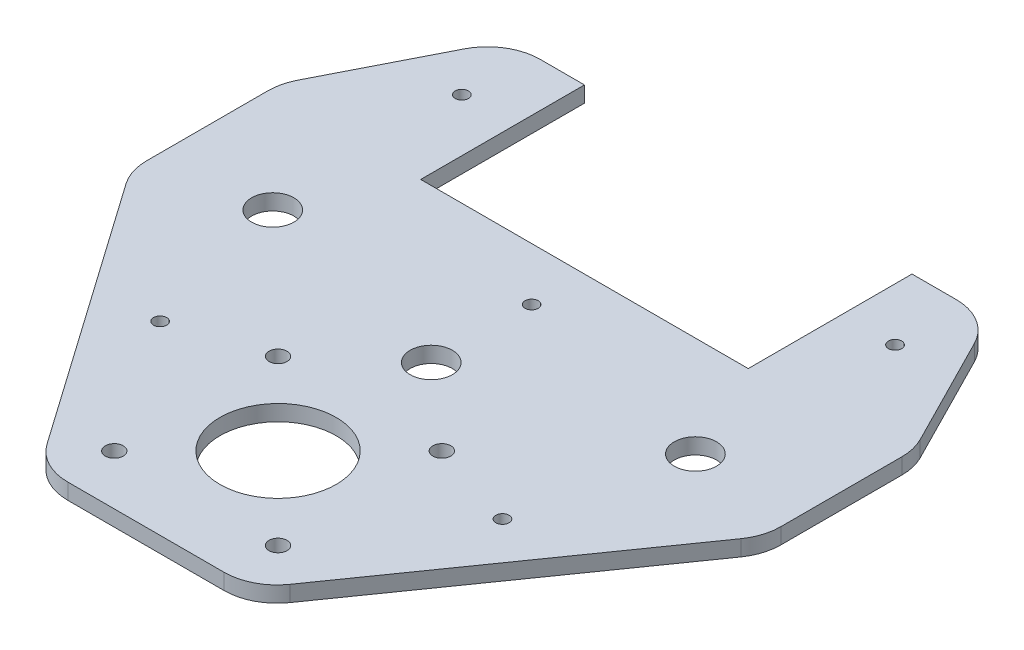
from build123d import *

# Parameters (mm, degrees)
SKETCH1_R           = 4
SKETCH1_R_2         = 1.7
SKETCH1_R_3         = 11
BOSS_EXTRUDE1_DEPTH = 3
FILLET1_R           = 10
SKETCH2_R           = 1.25
SKETCH2_R_2         = 1.255555556
CUT_EXTRUDE1_DEPTH  = 3


with BuildPart() as part:
    # Sketch1 → Boss-Extrude1 (new body)
    with BuildSketch(Plane(origin=(0, 0, 0), x_dir=(1, 0, 0), z_dir=(0, 1, 0))):
        Polygon((20, -64), (-20, -64), (-60, -7), (-60, 21.5), (-45.5, 50), (-31, 50), (-31, 19), (31, 19), (31, 50), (45.5, 50), (60, 21.5), (60, -7), align=None)
        with Locations((0, -10)):
            Circle(SKETCH1_R, mode=Mode.SUBTRACT)
        with Locations((-40, 0)):
            Circle(SKETCH1_R, mode=Mode.SUBTRACT)
        with Locations((40, 0)):
            Circle(SKETCH1_R, mode=Mode.SUBTRACT)
        with Locations((-15.5, -23.5)):
            Circle(SKETCH1_R_2, mode=Mode.SUBTRACT)
        with Locations((15.5, -23.5)):
            Circle(SKETCH1_R_2, mode=Mode.SUBTRACT)
        with Locations((15.5, -54.5)):
            Circle(SKETCH1_R_2, mode=Mode.SUBTRACT)
        with Locations((-15.5, -54.5)):
            Circle(SKETCH1_R_2, mode=Mode.SUBTRACT)
        with Locations((0, -39)):
            Circle(SKETCH1_R_3, mode=Mode.SUBTRACT)
    extrude(amount=BOSS_EXTRUDE1_DEPTH)

    # Fillet1
    fillet1_edges = [part.edges().sort_by_distance(p)[0] for p in [
        (45.5, 1.5, -50),
        (60, 1.5, -21.5),
        (60, 1.5, 7),
        (20, 1.5, 64),
        (-20, 1.5, 64),
        (-60, 1.5, 7),
        (-60, 1.5, -21.5),
        (-45.5, 1.5, -50),
    ]]
    fillet(fillet1_edges, radius=FILLET1_R)

    # Sketch2 → Cut-Extrude1 (cut)
    with BuildSketch(Plane(origin=(0, 3, 0), x_dir=(1, 0, 0), z_dir=(0, 1, 0))):
        with Locations((-32.400459523, -28.920654821)):
            Circle(SKETCH2_R)
        with Locations((32.400459523, -28.920654821)):
            Circle(SKETCH2_R)
        with Locations((0, 9)):
            Circle(SKETCH2_R)
        with Locations((-41, 36.792031786)):
            Circle(SKETCH2_R)
        with Locations((41, 36.792031786)):
            Circle(SKETCH2_R_2)
    extrude(amount=-CUT_EXTRUDE1_DEPTH, mode=Mode.SUBTRACT)


solid = part.part
